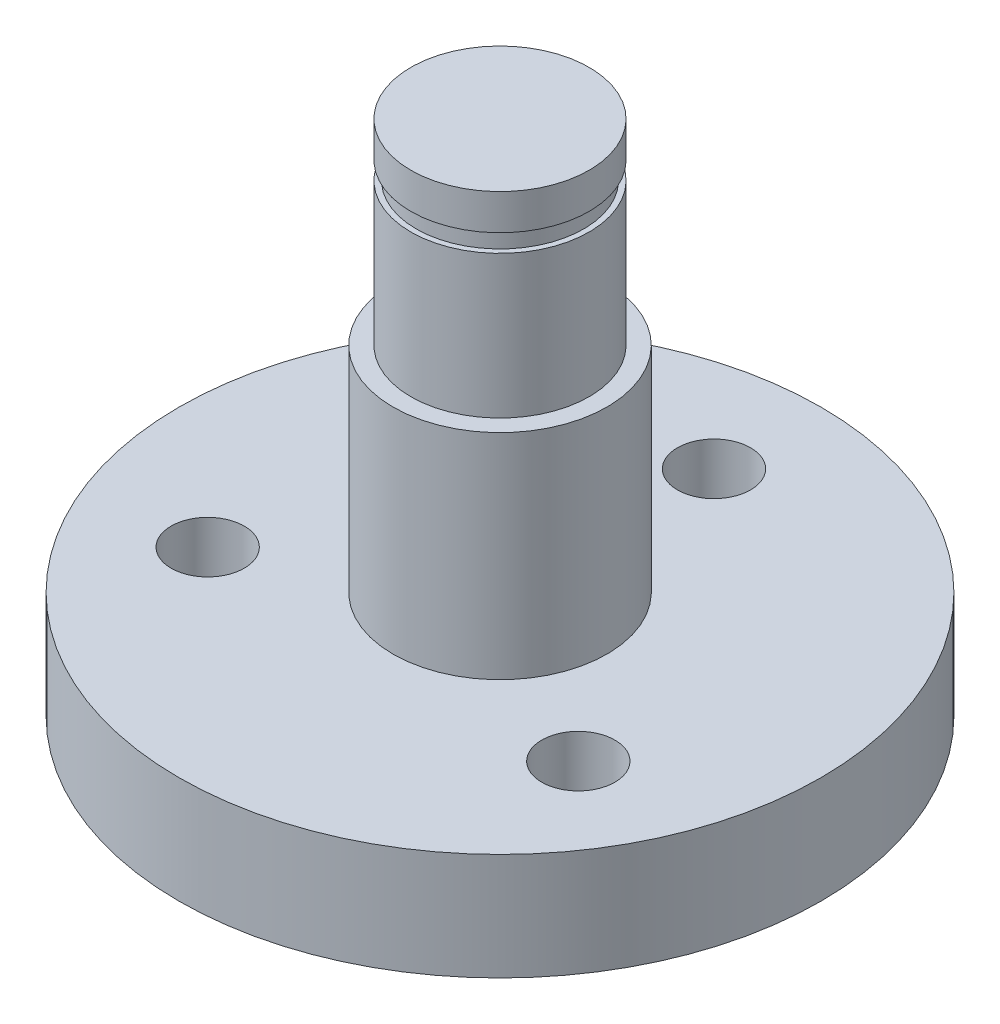
from build123d import *

# Parameters (mm, degrees)
SKETCH_1_R           = 3
SKETCH_1_R_2         = 2.5
EXTRUDE_1_DEPTH      = 6
SKETCH_1_8_R         = 2.5
EXTRUDE_2_DEPTH      = 11.5
SKETCH_1_9_R         = 9
EXTRUDE_3_DEPTH      = 3
SKETCH_6_W           = 0.15
SKETCH_6_H           = 0.5
HOLE_WIZARD_M2_5_1_D = 2.05


with BuildPart() as part:
    # 草图1 → 凸台-拉伸1 (new body)
    with BuildSketch(Plane(origin=(0, 0, 0), x_dir=(1, 0, 0), z_dir=(0, 1, 0))):
        Circle(SKETCH_1_R)
        Circle(SKETCH_1_R_2, mode=Mode.SUBTRACT)
    extrude(amount=EXTRUDE_1_DEPTH)

    # 草图1<8> → 凸台-拉伸2 (add)
    with BuildSketch(Plane(origin=(0, 0, 0), x_dir=(1, 0, 0), z_dir=(0, 1, 0))):
        Circle(SKETCH_1_8_R)
    extrude(amount=EXTRUDE_2_DEPTH)

    # 草图1<9> → 凸台-拉伸3 (add)
    with BuildSketch(Plane(origin=(0, 0, 0), x_dir=(1, 0, 0), z_dir=(0, 1, 0))):
        Circle(SKETCH_1_9_R)
    extrude(amount=-EXTRUDE_3_DEPTH)

    # 草图6 → 切除-旋转1 (revolve, cut)
    with BuildSketch(Plane(origin=(0, 0, 0), x_dir=(0, 0, -1), z_dir=(1, 0, 0))):
        with Locations((-2.425, 10.25)):
            Rectangle(SKETCH_6_W, SKETCH_6_H)
    revolve(axis=Axis((0, 9, 0), (0, -1, 0)), mode=Mode.SUBTRACT)

    # M2.5 螺纹孔1 (through all)
    with Locations(Plane(origin=(0, 0, 0), x_dir=(1, 0, 0), z_dir=(0, 1, 0))):
        with Locations((-5.196152423, -3), (0, 6), (5.196152423, -3)):
            Hole(HOLE_WIZARD_M2_5_1_D / 2)


solid = part.part
